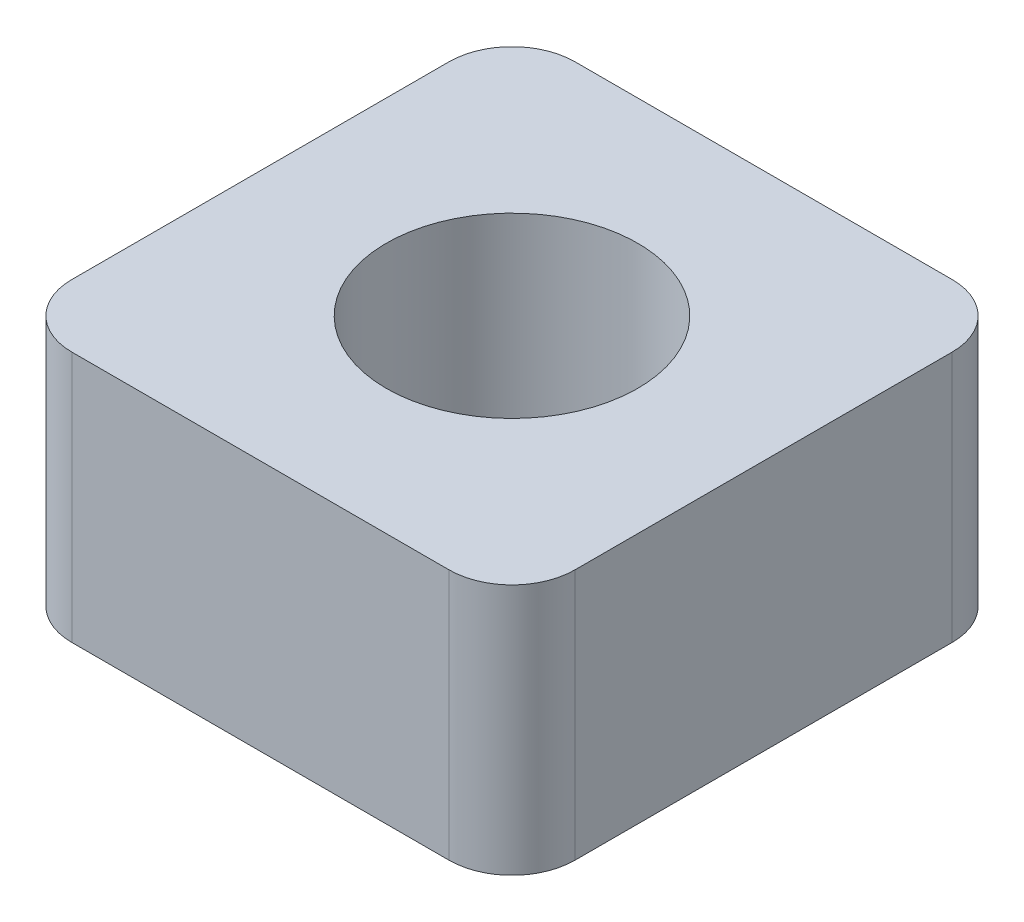
from build123d import *

# Parameters (mm, degrees)
SKETCH_1_W      = 8
SKETCH_1_H      = 8
SKETCH_1_R      = 2
EXTRUDE_1_DEPTH = 4
FILLET_1_R      = 1


with BuildPart() as part:
    # 草图1 → 凸台-拉伸1 (new body)
    with BuildSketch(Plane(origin=(0, 0, 0), x_dir=(1, 0, 0), z_dir=(0, 1, 0))):
        Rectangle(SKETCH_1_W, SKETCH_1_H)
        Circle(SKETCH_1_R, mode=Mode.SUBTRACT)
    extrude(amount=EXTRUDE_1_DEPTH)

    # 圆角1
    fillet_1_edges = [part.edges().sort_by_distance(p)[0] for p in [
        (4, 2, 4),
        (-4, 2, 4),
        (-4, 2, -4),
        (4, 2, -4),
    ]]
    fillet(fillet_1_edges, radius=FILLET_1_R)


solid = part.part
